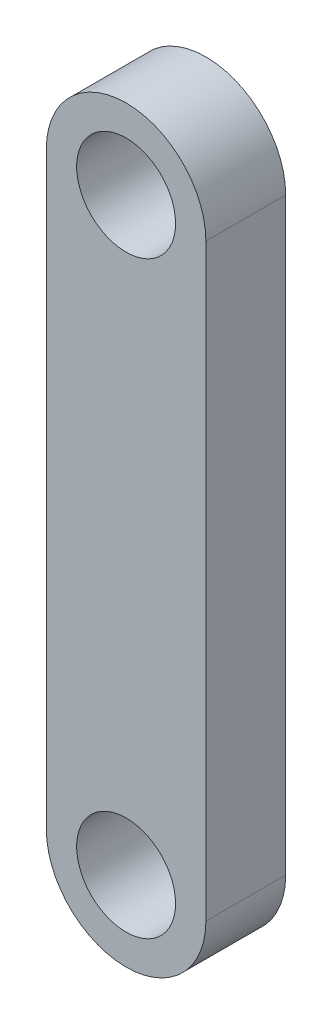
from build123d import *

# Parameters (mm, degrees)
SKETCH1_R           = 3.937
BOSS_EXTRUDE1_DEPTH = 6.35


with BuildPart() as part:
    # Sketch1 → Boss-Extrude1 (new body)
    with BuildSketch(Plane.XY):
        with BuildLine():
            Line((6.35, 33.503002032), (6.35, -13.359997968))
            ThreePointArc((6.35, -13.359997968), (0, -19.709997968), (-6.35, -13.359997968))
            Line((-6.35, -13.359997968), (-6.35, 33.503002032))
            ThreePointArc((-6.35, 33.503002032), (0, 39.853002032), (6.35, 33.503002032))
        make_face()
        with Locations((0, 33.503002032)):
            Circle(SKETCH1_R, mode=Mode.SUBTRACT)
        with Locations((0, -13.359997968)):
            Circle(SKETCH1_R, mode=Mode.SUBTRACT)
    extrude(amount=BOSS_EXTRUDE1_DEPTH)


solid = part.part
